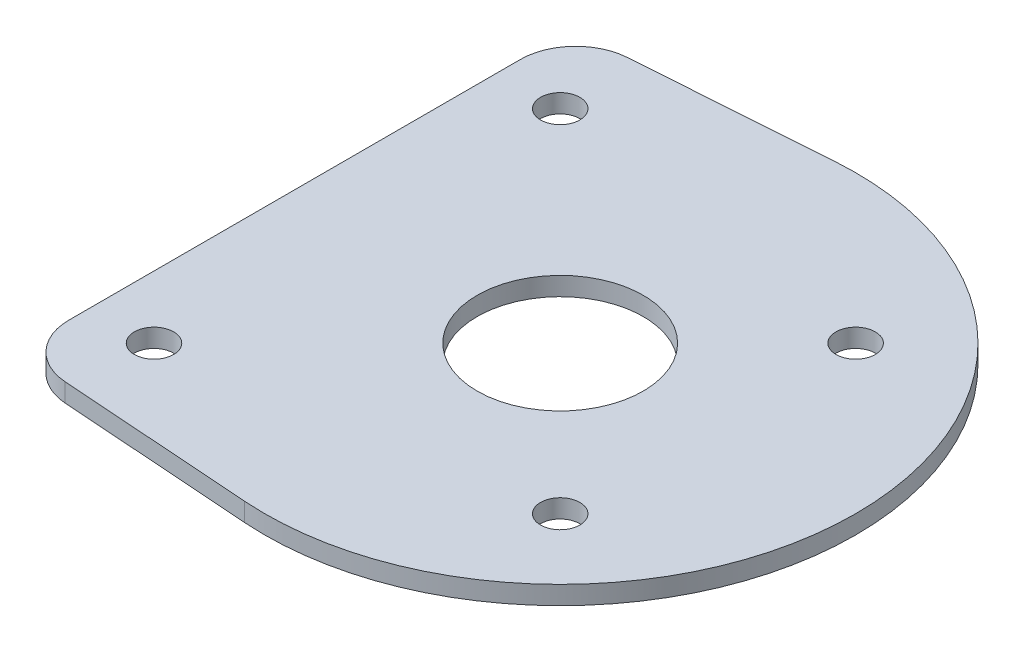
from build123d import *

# Parameters (mm, degrees)
SKETCH1_R               = 14.28115
SKETCH1_R_2             = 19.177
BOSS_EXTRUDE1_DEPTH     = 3.175
F_10_CLEARANCE_HOLE1_D  = 5.1054
F_1_4_CLEARANCE_HOLE1_D = 6.7564
SKETCH6_R               = 2.5527
CUT_EXTRUDE1_DEPTH      = 4.175
FILLET1_R               = 7.62
CUT_EXTRUDE2_DEPTH      = 4.175
FILLET2_R               = 9.525


with BuildPart() as part:
    # Sketch1 → Boss-Extrude1 (new body)
    with BuildSketch(Plane(origin=(0, 0, 0), x_dir=(1, 0, 0), z_dir=(0, 1, 0))):
        with BuildLine():
            Line((85.884602434, 50.671947857), (-3.15409287, 44.337954375))
            ThreePointArc((-3.15409287, 44.337954375), (-44.45, 0), (-3.15409287, -44.337954375))
            Line((-3.15409287, -44.337954375), (85.884602434, -50.671947857))
            ThreePointArc((85.884602434, -50.671947857), (140.28928, 0), (85.884602434, 50.671947857))
        make_face()
        with Locations((89.48928, 0)):
            Circle(SKETCH1_R, mode=Mode.SUBTRACT)
        Circle(SKETCH1_R_2, mode=Mode.SUBTRACT)
    extrude(amount=BOSS_EXTRUDE1_DEPTH)

    # #10 Clearance Hole1 (through all)
    with Locations(Plane(origin=(0, 3.175, 0), x_dir=(1, 0, 0), z_dir=(0, 1, 0))):
        with Locations((-17.960512242, 17.960512242), (17.960512242, 17.960512242), (17.960512242, -17.960512242), (-17.960512242, -17.960512242), (-31.8135, 0), (34.925, 34.314713318), (34.925, -34.314713318)):
            Hole(F_10_CLEARANCE_HOLE1_D / 2)

    # 1/4 Clearance Hole1 (through all)
    with Locations(Plane(origin=(0, 3.175, 0), x_dir=(1, 0, 0), z_dir=(0, 1, 0))):
        with Locations((54.56428, 34.925), (54.56428, -34.925), (114.88928, 25.4), (114.88928, -25.4)):
            Hole(F_1_4_CLEARANCE_HOLE1_D / 2)

    # Sketch6 → Cut-Extrude1 (cut, through all)
    with BuildSketch(Plane(origin=(0, 3.175, 0), x_dir=(1, 0, 0), z_dir=(0, 1, 0))):
        with BuildLine():
            Line((-9.48365621, 16.667861107), (-14.368409794, 21.552614691))
            ThreePointArc((-14.368409794, 21.552614691), (-21.552614691, 21.552614691), (-21.552614691, 14.368409794))
            Line((-21.552614691, 14.368409794), (-16.667861107, 9.48365621))
            ThreePointArc((-16.667861107, 9.48365621), (-13.560186743, 13.560186743), (-9.48365621, 16.667861107))
        make_face()
        with Locations((-17.960512242, 17.960512242)):
            Circle(SKETCH6_R, mode=Mode.SUBTRACT)
        with BuildLine():
            ThreePointArc((16.667861107, -9.48365621), (13.560186743, -13.560186743), (9.48365621, -16.667861107))
            Line((9.48365621, -16.667861107), (14.368409794, -21.552614691))
            ThreePointArc((14.368409794, -21.552614691), (21.552614691, -21.552614691), (21.552614691, -14.368409794))
            Line((21.552614691, -14.368409794), (16.667861107, -9.48365621))
        make_face()
        with Locations((17.960512242, -17.960512242)):
            Circle(SKETCH6_R, mode=Mode.SUBTRACT)
    extrude(amount=-CUT_EXTRUDE1_DEPTH, mode=Mode.SUBTRACT)

    # Fillet1
    fillet1_edges = [part.edges().sort_by_distance(p)[0] for p in [
        (9.48365621, 1.5875, 16.667861107),
        (16.667861107, 1.5875, 9.48365621),
        (-9.48365621, 1.5875, -16.667861107),
        (-16.667861107, 1.5875, -9.48365621),
    ]]
    fillet(fillet1_edges, radius=FILLET1_R)

    # Sketch7 → Cut-Extrude2 (cut, through all)
    with BuildSketch(Plane(origin=(0, 3.175, 0), x_dir=(1, 0, 0), z_dir=(0, 1, 0))):
        Polygon((43.815, 47.679219957), (43.815, -47.679219957), (-626.42496, 0), align=None)
    extrude(amount=-CUT_EXTRUDE2_DEPTH, mode=Mode.SUBTRACT)

    # Fillet2
    fillet2_edges = [part.edges().sort_by_distance(p)[0] for p in [
        (43.815, 1.5875, 47.679219957),
        (43.815, 1.5875, -47.679219957),
    ]]
    fillet(fillet2_edges, radius=FILLET2_R)


solid = part.part
